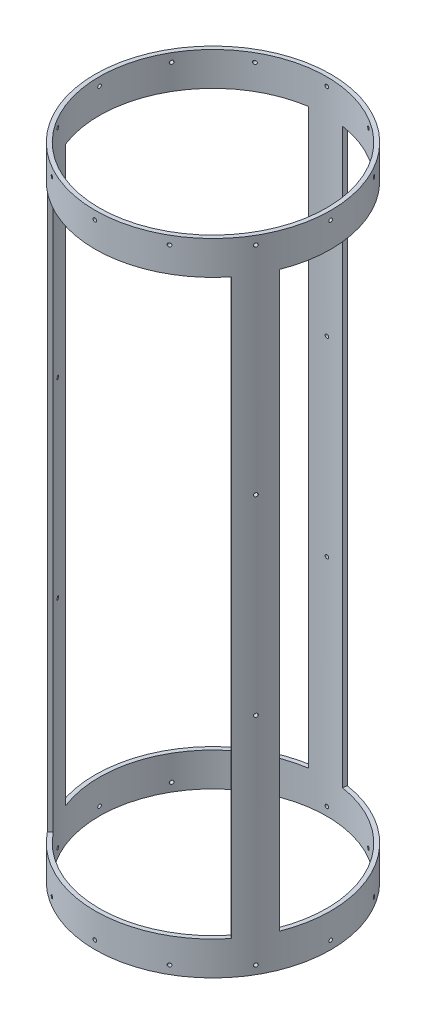
from build123d import *

# Parameters (mm, degrees)
SKETCH1_R               = 88.9
SKETCH1_R_2             = 85.725
BOSS_EXTRUDE1_DEPTH     = 241.427
CUT_EXTRUDE5_START      = -25.4
CUT_EXTRUDE5_DEPTH      = 432.054
CIRPATTERN5_COUNT       = 3
CUT_EXTRUDE2_REACH      = 274.201
CUT_EXTRUDE2_END_RADIUS = 88.9
SKETCH3_R               = 1.35255
CIRPATTERN2_COUNT       = 12
SKETCH4_R               = 1.35255
CUT_EXTRUDE3_DEPTH      = 15.24
CIRPATTERN3_COUNT       = 12
CUT_EXTRUDE4_REACH      = 314.735
SKETCH5_R               = 1.35255
CIRPATTERN4_COUNT       = 3


with BuildPart() as part:
    # Sketch1 → Boss-Extrude1 (new, symmetric)
    with BuildSketch(Plane(origin=(0, 0, 0), x_dir=(1, 0, 0), z_dir=(0, 1, 0))):
        with Locations(Location((0, 0, 0), (0, 0, 270))):
            Circle(SKETCH1_R)
        with Locations(Location((0, 0, 0), (0, 0, 270))):
            Circle(SKETCH1_R_2, mode=Mode.SUBTRACT)
    extrude(amount=BOSS_EXTRUDE1_DEPTH, both=True)

    # Sketch6 → Cut-Extrude5 (cut)
    with BuildSketch(Plane(origin=(0, -241.427, 0), x_dir=(-1, 0, 0), z_dir=(0, -1, 0)).offset(CUT_EXTRUDE5_START)):
        with BuildLine():
            Line((82.79008563, -32.388450433), (79.833296857, -31.23172006))
            ThreePointArc((79.833296857, -31.23172006), (74.185462692, 42.956870815), (12.653594621, 84.785978606))
            Line((12.653594621, 84.785978606), (13.122246274, 87.926200036))
            ThreePointArc((13.122246274, 87.926200036), (76.933072421, 44.54786603), (82.79008563, -32.388450433))
        make_face()
    cut_extrude5 = extrude(amount=-CUT_EXTRUDE5_DEPTH, mode=Mode.SUBTRACT)

    # CirPattern5: Cut-Extrude5 ×3 about axis
    cirpattern5_axis = Axis((0, 0, 0), (0, 1, 0))
    for i in range(1, CIRPATTERN5_COUNT):
        add(cut_extrude5.rotate(cirpattern5_axis, i * 360 / CIRPATTERN5_COUNT), mode=Mode.SUBTRACT)

    # Cut-Extrude2: up to this cylinder (the profile starts inside it)
    cut_extrude2_end = Plane(origin=(0, -235.077, 0), z_dir=(0, -1, 0)) * Cylinder(CUT_EXTRUDE2_END_RADIUS, 727.202, mode=Mode.PRIVATE)
    # Sketch3 → Cut-Extrude2 (cut, up to the surface)
    with BuildSketch(Plane(origin=(0, 0, 0), x_dir=(-1, 0, 0), z_dir=(0, 0, -1)), mode=Mode.PRIVATE) as cut_extrude2_sk1:
        with Locations(Location((-0.169185452, -235.077, 0), (0, 0, 180))):
            Circle(SKETCH3_R)
    cut_extrude2_tool1 = extrude(cut_extrude2_sk1.sketch, amount=CUT_EXTRUDE2_REACH, mode=Mode.PRIVATE) & cut_extrude2_end
    cut_extrude2 = cut_extrude2_tool1.solids().sort_by_distance((0.169185, -235.077, 0))[0]
    add(cut_extrude2, mode=Mode.SUBTRACT)

    # CirPattern2: Cut-Extrude2 ×12 about axis
    cirpattern2_axis = Axis((0, 241.427, 0), (0, -1, 0))
    for i in range(1, CIRPATTERN2_COUNT):
        add(cut_extrude2.rotate(cirpattern2_axis, i * 360 / CIRPATTERN2_COUNT), mode=Mode.SUBTRACT)

    # Sketch4 → Cut-Extrude3 (cut)
    with BuildSketch(Plane(origin=(0, 0, -88.9), x_dir=(-1, 0, 0), z_dir=(0, 0, -1))):
        with Locations(Location((-0.169185452, 235.077, 0), (0, 0, 82.814261444))):
            Circle(SKETCH4_R)
    cut_extrude3 = extrude(amount=-CUT_EXTRUDE3_DEPTH, mode=Mode.SUBTRACT)

    # CirPattern3: Cut-Extrude3 ×12 about axis
    cirpattern3_axis = Axis((0, 241.427, 0), (0, 1, 0))
    for i in range(1, CIRPATTERN3_COUNT):
        add(cut_extrude3.rotate(cirpattern3_axis, i * 360 / CIRPATTERN3_COUNT), mode=Mode.SUBTRACT)

    # Sketch5 → Cut-Extrude4 (cut, up to next)
    with BuildSketch(Plane.XY.offset(88.9), mode=Mode.PRIVATE) as cut_extrude4_sk1:
        with Locations((0.169185452, 72.009)):
            Circle(SKETCH5_R)
    cut_extrude4_tool1 = extrude(cut_extrude4_sk1.sketch, amount=-CUT_EXTRUDE4_REACH, mode=Mode.PRIVATE) & part.part
    # Sketch5 → Cut-Extrude4 (cut, up to next)
    with BuildSketch(Plane.XY.offset(88.9), mode=Mode.PRIVATE) as cut_extrude4_sk2:
        with Locations((0.169185452, -72.009)):
            Circle(SKETCH5_R)
    cut_extrude4_tool2 = extrude(cut_extrude4_sk2.sketch, amount=-CUT_EXTRUDE4_REACH, mode=Mode.PRIVATE) & part.part
    cut_extrude4_1 = cut_extrude4_tool1.solids().sort_by_distance((0.169185, 72.009, 88.9))[0]
    add(cut_extrude4_1, mode=Mode.SUBTRACT)
    cut_extrude4_2 = cut_extrude4_tool2.solids().sort_by_distance((0.169185, -72.009, 88.9))[0]
    add(cut_extrude4_2, mode=Mode.SUBTRACT)
    cut_extrude4 = cut_extrude4_1 + cut_extrude4_2  # Cut-Extrude4 as one shape, for the pattern or mirror that repeats it

    # CirPattern4: Cut-Extrude4 ×3 about axis
    cirpattern4_axis = Axis((0, 241.427, 0), (0, -1, 0))
    for i in range(1, CIRPATTERN4_COUNT):
        add(cut_extrude4.rotate(cirpattern4_axis, i * 360 / CIRPATTERN4_COUNT), mode=Mode.SUBTRACT)


solid = part.part
